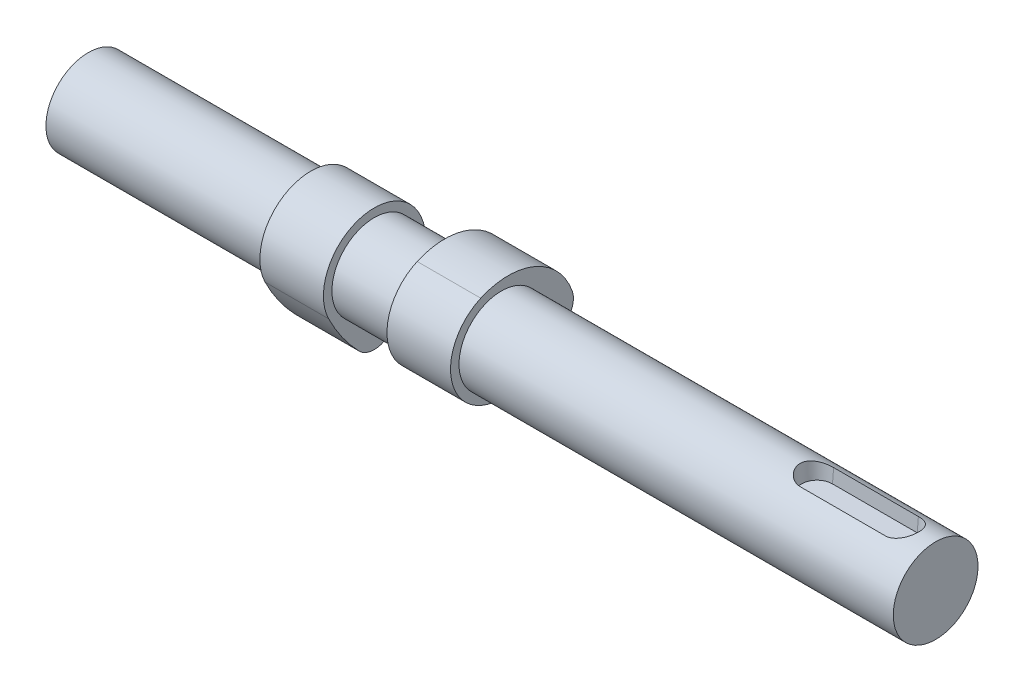
from build123d import *

# Parameters (mm, degrees)
SKETCH1_R                = 10
BOSS_EXTRUDE1_DEPTH      = 125
BOSS_EXTRUDE1_DEPTH_BACK = 75
BOSS_EXTRUDE2_START      = 15
BOSS_EXTRUDE2_DEPTH      = 7.5
BODY_MOVE_COPY1_ANGLE    = 90
CUT_EXTRUDE1_START       = 10
CUT_EXTRUDE1_DEPTH       = 4
CUT_EXTRUDE1_TAPER       = 5


with BuildPart() as part:
    # Sketch1 → Boss-Extrude1 (new body, two sides)
    with BuildSketch(Plane(origin=(0, 0, 0), x_dir=(0, 0, -1), z_dir=(1, 0, 0))) as boss_extrude1_sk:
        Circle(SKETCH1_R)
    extrude(amount=BOSS_EXTRUDE1_DEPTH)
    extrude(boss_extrude1_sk.sketch, amount=-BOSS_EXTRUDE1_DEPTH_BACK)

    # Sketch3 → Cut-Extrude1 (cut)
    with BuildSketch(Plane(origin=(0, 0, 0), x_dir=(1, 0, 0), z_dir=(0, 1, 0)).offset(CUT_EXTRUDE1_START)):
        with BuildLine():
            ThreePointArc((97, 4), (93, 0), (97, -4))
            Line((97, -4), (117, -4))
            ThreePointArc((117, -4), (121, 0), (117, 4))
            Line((117, 4), (97, 4))
        make_face()
    extrude(amount=-CUT_EXTRUDE1_DEPTH, taper=CUT_EXTRUDE1_TAPER, mode=Mode.SUBTRACT)


with BuildPart() as body_2:
    # Sketch2 → Boss-Extrude2 (new body, symmetric)
    with BuildSketch(Plane(origin=(0, 0, 0), x_dir=(0, 0, -1), z_dir=(1, 0, 0)).offset(BOSS_EXTRUDE2_START)):
        with BuildLine():
            ThreePointArc((-4.867089568, 10.968657125), (-10.868088345, -5.087696504), (5.306226617, -10.763083159))
            ThreePointArc((5.306226617, -10.763083159), (10.673744978, -7.573594418), (15.479542802, -3.587694386))
            ThreePointArc((15.479542802, -3.587694386), (16.864464688, -1.143374761), (16.712672037, 1.661917746))
            ThreePointArc((16.712672037, 1.661917746), (7.958571112, 11.035699457), (-4.867089568, 10.968657125))
        make_face()
    extrude(amount=BOSS_EXTRUDE2_DEPTH, both=True)


with BuildPart() as body_3:
    # Mirror1: mirrored copy
    add(body_2.part.mirror(Plane(origin=(0, 0, 0), x_dir=(0, 0, 1), z_dir=(1, 0, 0))))


with BuildPart() as body_3_1:
    # Body-Move/Copy1: moved
    add(body_3.part.rotate(Axis((0, 0, 0), (-1, 0, 0)), BODY_MOVE_COPY1_ANGLE))


solid = Compound([part.part, body_2.part, body_3_1.part])
